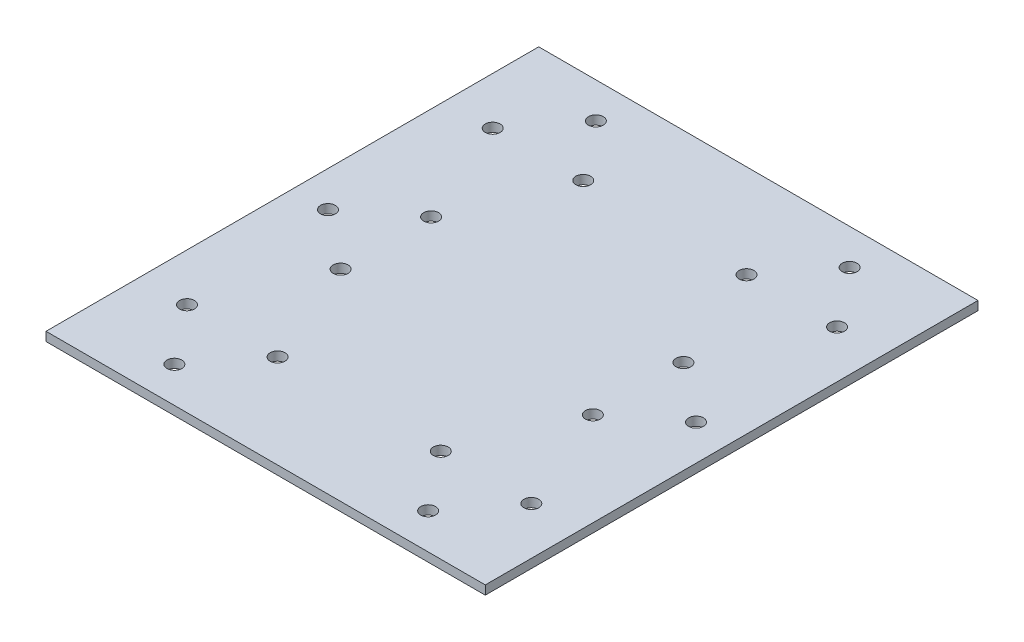
from build123d import *

# Parameters (mm, degrees)
SKETCH_1_W          = 148
SKETCH_1_H          = 166
EXTRUDE_1_DEPTH     = 3
SKETCH_2_R          = 2.5
CUT_EXTRUDE_1_DEPTH = 4


with BuildPart() as part:
    # 草图1 → 凸台-拉伸1 (new body)
    with BuildSketch(Plane(origin=(0, 0, 0), x_dir=(1, 0, 0), z_dir=(0, 1, 0))):
        Rectangle(SKETCH_1_W, SKETCH_1_H)
    extrude(amount=EXTRUDE_1_DEPTH)

    # 草图2 → 切除-拉伸1 (cut, through all)
    with BuildSketch(Plane(origin=(0, 3, 0), x_dir=(1, 0, 0), z_dir=(0, 1, 0))):
        with Locations((-58, 51.5)):
            Circle(SKETCH_2_R)
        with Locations((-27.5, 51.5)):
            Circle(SKETCH_2_R)
        with Locations((-27.5, -51.5)):
            Circle(SKETCH_2_R)
        with Locations((-58, -51.5)):
            Circle(SKETCH_2_R)
        with Locations((58, -51.5)):
            Circle(SKETCH_2_R)
        with Locations((27.5, -51.5)):
            Circle(SKETCH_2_R)
        with Locations((27.5, 51.5)):
            Circle(SKETCH_2_R)
        with Locations((58, 51.5)):
            Circle(SKETCH_2_R)
        with Locations((-42.75, 71)):
            Circle(SKETCH_2_R)
        with Locations((-42.75, -71)):
            Circle(SKETCH_2_R)
        with Locations((42.75, -71)):
            Circle(SKETCH_2_R)
        with Locations((42.75, 71)):
            Circle(SKETCH_2_R)
        with Locations((-62, 0)):
            Circle(SKETCH_2_R)
        with Locations((-42.5, -15.25)):
            Circle(SKETCH_2_R)
        with Locations((-42.5, 15.25)):
            Circle(SKETCH_2_R)
        with Locations((42.5, 15.25)):
            Circle(SKETCH_2_R)
        with Locations((42.5, -15.25)):
            Circle(SKETCH_2_R)
        with Locations((62, 0)):
            Circle(SKETCH_2_R)
    extrude(amount=-CUT_EXTRUDE_1_DEPTH, mode=Mode.SUBTRACT)


solid = part.part
